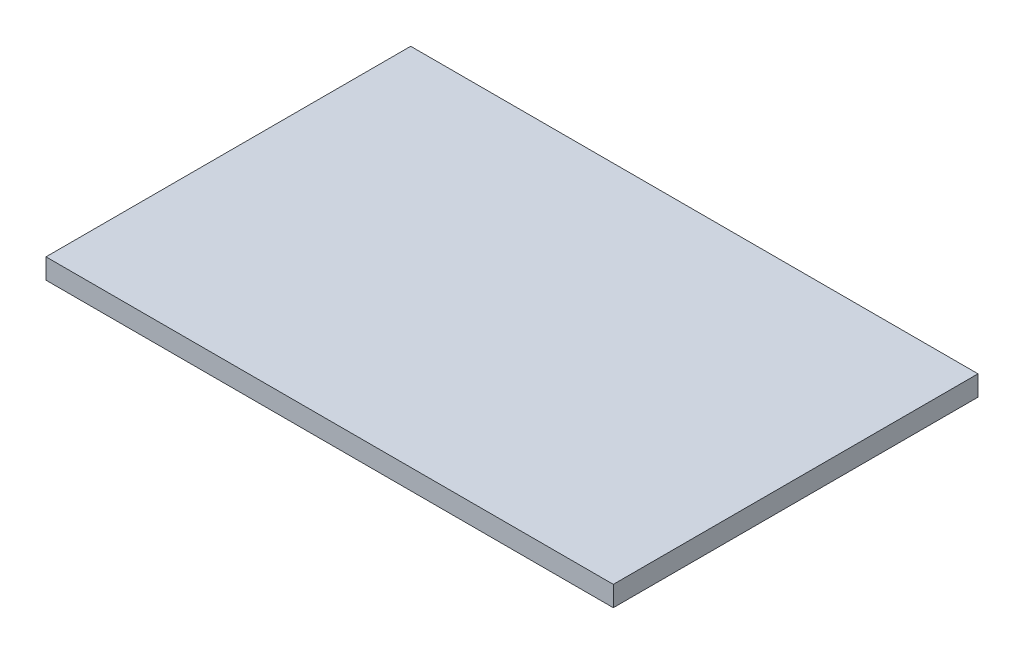
from build123d import *

# Parameters (mm, degrees)
SKETCH1_W           = 7
SKETCH1_H           = 4.5
BOSS_EXTRUDE1_DEPTH = 0.25


with BuildPart() as part:
    # Sketch1 → Boss-Extrude1 (new body)
    with BuildSketch(Plane(origin=(0, 0, 0), x_dir=(1, 0, 0), z_dir=(0, 1, 0))):
        with Locations((3.5, 2.25)):
            Rectangle(SKETCH1_W, SKETCH1_H)
    extrude(amount=BOSS_EXTRUDE1_DEPTH)


solid = part.part
